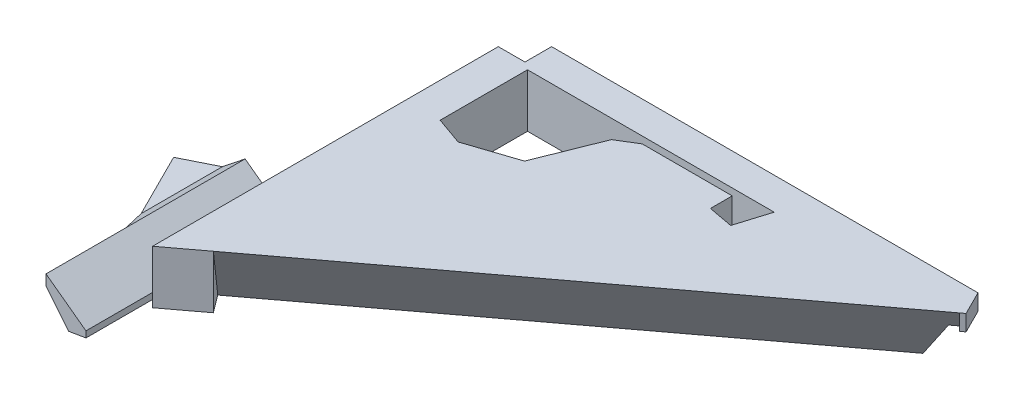
from build123d import *

# Parameters (mm, degrees)
BOSS_EXTRUDE1_DEPTH = 25.4
SKETCH2_W           = 12.7
SKETCH2_H           = 17.78
CUT_EXTRUDE1_DEPTH  = 209.879612663
CUT_EXTRUDE2_DEPTH  = 95.896126628
CUT_EXTRUDE3_DEPTH  = 254


with BuildPart() as part:
    # Sketch1 → Boss-Extrude1 (new body)
    with BuildSketch(Plane(origin=(0, 0, 0), x_dir=(1, 0, 0), z_dir=(0, 1, 0))):
        Polygon((0, 0), (0, 101.6), (12.7, 101.6), (12.7, 114.3), (215.9, 114.3), (221.579612663, 102.940774674), (0, -63.146126628), (0, -94.896126628), (-19.05, -94.896126628), (-19.05, -56.796126628), (-41.768450651, -11.359225326), (-19.05, 0), align=None)
        Polygon((16.51, 99.016534905), (16.51, 57.380699548), (29.761390928, 52.687033829), (53.490710304, 60.611873008), (65.339387315, 90.173417518), (74.422473615, 95.748477248), (117.328122685, 95.748477248), (117.328122685, 85.363664607), (129.190216348, 83.158940906), (134.056716313, 99.016534905), align=None, mode=Mode.SUBTRACT)
    extrude(amount=BOSS_EXTRUDE1_DEPTH)

    # Sketch2 → Cut-Extrude1 (cut, through all)
    with BuildSketch(Plane.ZY.offset(-12.7)):
        with Locations((-107.95, 8.89)):
            Rectangle(SKETCH2_W, SKETCH2_H)
    extrude(amount=-CUT_EXTRUDE1_DEPTH, mode=Mode.SUBTRACT)

    # Sketch3 → Cut-Extrude2 (cut, through all)
    with BuildSketch(Plane(origin=(0, 0, 0), x_dir=(-1, 0, 0), z_dir=(0, 0, -1))):
        Polygon((26.279490994, 10.727129804), (19.05, 15.314148044), (19.05, 0), (41.768450651, 0), (41.768450651, 10.727129804), align=None)
        Polygon((8.25422712, 2.027835054), (0, 3.409743564), (0, 0), (19.05, 0), (19.05, 15.314148044), align=None)
        Polygon((19.05, 25.4), (0, 25.4), (0, 6.35), (19.05, 20.338025164), align=None)
        Polygon((41.768450651, 25.4), (19.05, 25.4), (19.05, 20.338025164), (26.279490994, 15.314148044), (41.768450651, 15.314148044), align=None)
    extrude(amount=-CUT_EXTRUDE2_DEPTH, mode=Mode.SUBTRACT)

    # Sketch4 → Cut-Extrude3 (cut)
    with BuildSketch(Plane(origin=(189.48572038, 0, -142.030648763), x_dir=(0, 1, 0), z_dir=(0.800169507, 0, -0.599773925))):
        Polygon((0, 40.087892142), (25.4, 50.527604994), (0, 50.527604994), align=None)
    extrude(amount=-CUT_EXTRUDE3_DEPTH, mode=Mode.SUBTRACT)


solid = part.part
